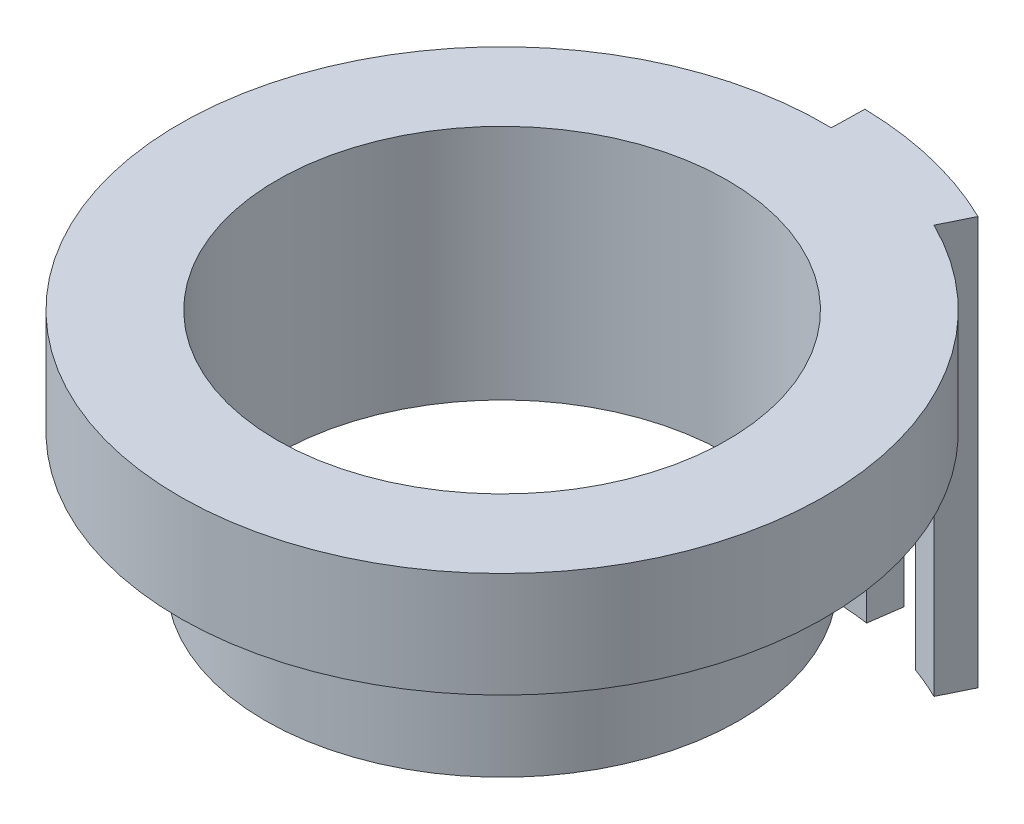
from build123d import *
from build123d.topology import SkipClean

# Parameters (mm, degrees)
SKETCH1_R           = 24.5
SKETCH1_R_2         = 17.1
BOSS_EXTRUDE1_DEPTH = 8
BOSS_EXTRUDE2_START = -10
SKETCH1_3_R         = 18
SKETCH1_3_R_2       = 17.1
BOSS_EXTRUDE2_DEPTH = 10
BOSS_EXTRUDE3_START = -4
BOSS_EXTRUDE3_DEPTH = 4
BOSS_EXTRUDE4_START = 27
BOSS_EXTRUDE4_DEPTH = 27


with BuildPart() as part:
    # Sketch1 → Boss-Extrude1 (new body)
    with BuildSketch(Plane(origin=(0, 0, 0), x_dir=(1, 0, 0), z_dir=(0, 1, 0))):
        Circle(SKETCH1_R)
        Circle(SKETCH1_R_2, mode=Mode.SUBTRACT)
    extrude(amount=BOSS_EXTRUDE1_DEPTH)

    # Sketch1_3 → Boss-Extrude2 (add)
    with BuildSketch(Plane(origin=(0, 0, 0), x_dir=(1, 0, 0), z_dir=(0, 1, 0)).offset(BOSS_EXTRUDE2_START)):
        Circle(SKETCH1_3_R)
        Circle(SKETCH1_3_R_2, mode=Mode.SUBTRACT)
    extrude(amount=BOSS_EXTRUDE2_DEPTH)

    # Sketch2 → Boss-Extrude3 (add)
    with BuildSketch(Plane(origin=(0, 8, 0), x_dir=(1, 0, 0), z_dir=(0, 1, 0)).offset(BOSS_EXTRUDE3_START)):
        with BuildLine():
            Line((0.558039299, 26.994232572), (0.506368994, 24.494766593))
            ThreePointArc((0.506368994, 24.494766593), (5.796003851, 23.804544511), (10.810861841, 21.985796921))
            Line((10.810861841, 21.985796921), (11.914011009, 24.229245586))
            ThreePointArc((11.914011009, 24.229245586), (6.387432816, 26.233579665), (0.558039299, 26.994232572))
        make_face()
    extrude(amount=BOSS_EXTRUDE3_DEPTH)

    # Sketch3 → Boss-Extrude4 (add)
    with SkipClean():  # the faces are left unmerged after this step: merging them gives an invalid solid
        with BuildSketch(Plane.XZ.offset(-4).offset(BOSS_EXTRUDE4_START)):
            with BuildLine():
                Line((0.506368994, -24.494766593), (0.558039299, -26.994232572))
                ThreePointArc((0.558039299, -26.994232572), (2.171691116, -26.912520463), (3.777566106, -26.734434617))
                Line((3.777566106, -26.734434617), (3.427791467, -24.259024005))
                ThreePointArc((3.427791467, -24.259024005), (1.970608605, -24.420620421), (0.506368994, -24.494766593))
            make_face()
            with BuildLine():
                Line((8.396620698, -23.016228207), (9.253418728, -25.364822922))
                ThreePointArc((9.253418728, -25.364822922), (10.598934115, -24.832692073), (11.914011009, -24.229245586))
                Line((11.914011009, -24.229245586), (10.810861841, -21.985796921))
                ThreePointArc((10.810861841, -21.985796921), (9.617551327, -22.533368733), (8.396620698, -23.016228207))
            make_face()
        extrude(amount=-BOSS_EXTRUDE4_DEPTH)


solid = part.part
